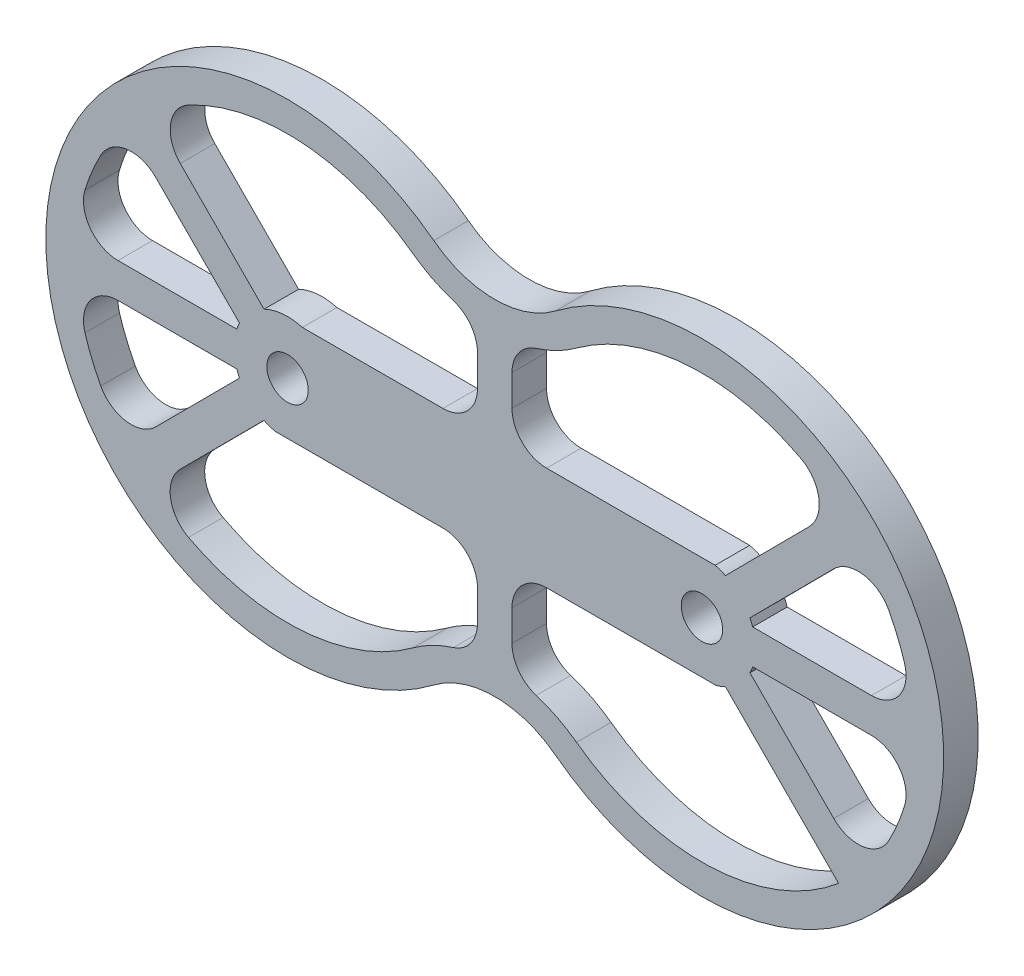
from build123d import *

# Parameters (mm, degrees)
SKETCH1_R           = 6
BOSS_EXTRUDE2_DEPTH = 10
FILLET2_R           = 10


with BuildPart() as part:
    # Sketch1 → Boss-Extrude2 (new body)
    with BuildSketch(Plane.XY):
        with BuildLine():
            ThreePointArc((-18.165151778, 55.726150839), (-130.527825355, 0), (-18.165151778, -55.726150839))
            ThreePointArc((-18.165151778, -55.726150839), (-0.527825355, -49.783359328), (17.109501067, -55.726150839))
            ThreePointArc((17.109501067, -55.726150839), (129.472174645, 0), (17.109501067, 55.726150839))
            ThreePointArc((17.109501067, 55.726150839), (-0.527825355, 49.783359328), (-18.165151778, 55.726150839))
        make_face()
        with Locations((-60.527825355, 0)):
            Circle(SKETCH1_R, mode=Mode.SUBTRACT)
        with Locations((59.472174645, 0)):
            Circle(SKETCH1_R, mode=Mode.SUBTRACT)
        with BuildLine():
            Line((-56.235975609, 14.912672635), (-5.527825355, 14.965504266))
            Line((-5.527825355, 14.965504266), (-5.527825355, 41.980686961))
            ThreePointArc((-5.527825355, 41.980686961), (-15.345309937, 44.512654742), (-24.210827936, 49.431643964))
            ThreePointArc((-24.210827936, 49.431643964), (-62.58583764, 61.303966527), (-100.078223296, 46.884728315))
            Line((-100.078223296, 46.884728315), (-67.337537784, 13.944016494))
            ThreePointArc((-67.337537784, 13.944016494), (-61.876707041, 15.459246345), (-56.235975609, 14.912672635))
        make_face(mode=Mode.SUBTRACT)
        with BuildLine():
            Line((-64.123905218, -15.095561897), (-5.527825355, -15.034512017))
            Line((-5.527825355, -15.034512017), (-5.527825355, -41.980686961))
            ThreePointArc((-5.527825355, -41.980686961), (-15.345309937, -44.512654742), (-24.210827936, -49.431643964))
            ThreePointArc((-24.210827936, -49.431643964), (-62.602390706, -61.303408593), (-100.103536918, -46.863362884))
            Line((-100.103536918, -46.863362884), (-67.345067046, -13.940336979))
            ThreePointArc((-67.345067046, -13.940336979), (-65.766427516, -14.607012931), (-64.123905218, -15.095561897))
        make_face(mode=Mode.SUBTRACT)
        with BuildLine():
            Line((-107.170792468, 39.835227443), (-74.430106955, 6.894515622))
            ThreePointArc((-74.430106955, 6.894515622), (-74.855512615, 5.960298411), (-75.218222877, 5))
            Line((-75.218222877, 5), (-121.6621997, 5))
            ThreePointArc((-121.6621997, 5), (-117.161402857, 23.559491206), (-107.170792468, 39.835227443))
        make_face(mode=Mode.SUBTRACT)
        with BuildLine():
            Line((-121.6621997, -5), (-75.218222877, -5))
            ThreePointArc((-75.218222877, -5), (-74.857121477, -5.956429468), (-74.433828207, -6.887006899))
            Line((-74.433828207, -6.887006899), (-107.192298079, -39.810032805))
            ThreePointArc((-107.192298079, -39.810032805), (-117.167762266, -23.544198292), (-121.6621997, -5))
        make_face(mode=Mode.SUBTRACT)
        with BuildLine():
            Line((4.472174645, 41.980686961), (4.472174645, 14.975923031))
            Line((4.472174645, 14.975923031), (63.304903434, 15.03721947))
            ThreePointArc((63.304903434, 15.03721947), (64.821395332, 14.56686711), (66.281887074, 13.944016494))
            Line((66.281887074, 13.944016494), (99.022572586, 46.884728315))
            ThreePointArc((99.022572586, 46.884728315), (61.530186929, 61.303966527), (23.155177226, 49.431643964))
            ThreePointArc((23.155177226, 49.431643964), (14.289659226, 44.512654742), (4.472174645, 41.980686961))
        make_face(mode=Mode.SUBTRACT)
        with BuildLine():
            Line((99.047886208, -46.863362884), (66.289416336, -13.940336979))
            ThreePointArc((66.289416336, -13.940336979), (64.962019266, -14.514454361), (63.586938832, -14.962502967))
            Line((63.586938832, -14.962502967), (4.472174645, -15.024093252))
            Line((4.472174645, -15.024093252), (4.472174645, -41.980686961))
            ThreePointArc((4.472174645, -41.980686961), (14.289659226, -44.512654742), (23.155177226, -49.431643964))
            ThreePointArc((23.155177226, -49.431643964), (61.546739995, -61.303408593), (99.047886208, -46.863362884))
        make_face(mode=Mode.SUBTRACT)
        with BuildLine():
            Line((106.136647368, -39.810032805), (73.378177497, -6.887006899))
            ThreePointArc((73.378177497, -6.887006899), (73.801470767, -5.956429468), (74.162572167, -5))
            Line((74.162572167, -5), (120.606548989, -5))
            ThreePointArc((120.606548989, -5), (116.112111556, -23.544198292), (106.136647368, -39.810032805))
        make_face(mode=Mode.SUBTRACT)
        with BuildLine():
            Line((120.606548989, 5), (74.162572167, 5))
            ThreePointArc((74.162572167, 5), (73.799861904, 5.960298411), (73.374456245, 6.894515622))
            Line((73.374456245, 6.894515622), (106.115141757, 39.835227443))
            ThreePointArc((106.115141757, 39.835227443), (116.105752147, 23.559491206), (120.606548989, 5))
        make_face(mode=Mode.SUBTRACT)
    extrude(amount=BOSS_EXTRUDE2_DEPTH)

    # Fillet2
    fillet2_edges = [part.edges().sort_by_distance(p)[0] for p in [
        (4.472174645, -15.024093252, 5),
        (4.472174645, -41.980686961, 5),
        (106.136647368, -39.810032805, 5),
        (120.606548989, -5, 5),
        (120.606548989, 5, 5),
        (106.115141757, 39.835227443, 5),
        (-100.103536918, -46.863362884, 5),
        (-5.527825355, -41.980686961, 5),
        (-5.527825355, -15.034512017, 5),
        (-121.6621997, -5, 5),
        (-107.192298079, -39.810032805, 5),
        (-107.170792468, 39.835227443, 5),
        (-121.6621997, 5, 5),
        (-5.527825355, 14.965504266, 5),
        (-5.527825355, 41.980686961, 5),
        (-100.078223296, 46.884728315, 5),
        (99.022572586, 46.884728315, 5),
        (4.472174645, 41.980686961, 5),
        (4.472174645, 14.975923031, 5),
    ]]
    fillet(fillet2_edges, radius=FILLET2_R)


solid = part.part
